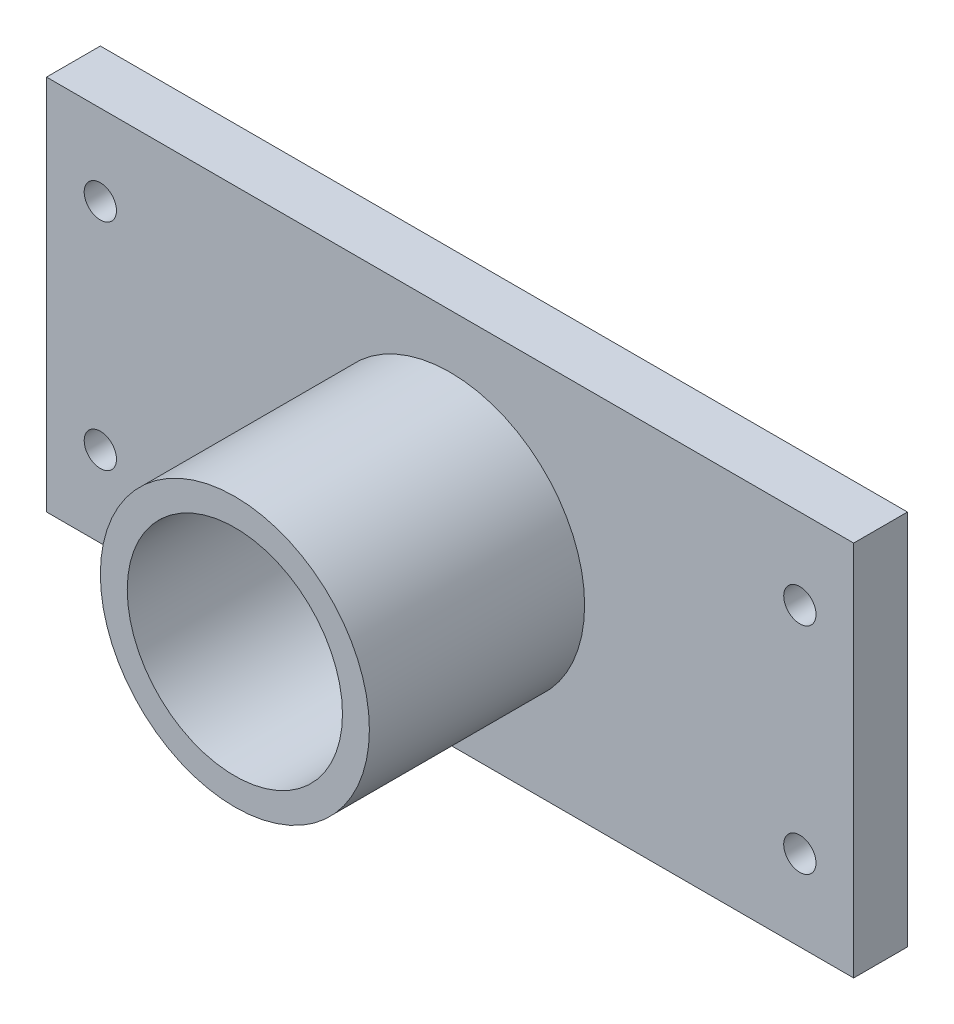
from build123d import *

# Parameters (mm, degrees)
SKETCH1_W           = 150
SKETCH1_H           = 70
SKETCH1_R           = 25
SKETCH1_R_2         = 20
BOSS_EXTRUDE1_DEPTH = 10
BOSS_EXTRUDE2_START = 10
SKETCH1_3_R         = 25
SKETCH1_3_R_2       = 20
BOSS_EXTRUDE2_DEPTH = 40
SKETCH6_R           = 3
CUT_EXTRUDE1_DEPTH  = 11


with BuildPart() as part:
    # Sketch1 → Boss-Extrude1 (new body)
    with BuildSketch(Plane.XY):
        Rectangle(SKETCH1_W, SKETCH1_H)
        Circle(SKETCH1_R, mode=Mode.SUBTRACT)
        Circle(SKETCH1_R)
        Circle(SKETCH1_R_2, mode=Mode.SUBTRACT)
    extrude(amount=BOSS_EXTRUDE1_DEPTH)

    # Sketch1_3 → Boss-Extrude2 (add)
    with BuildSketch(Plane.XY.offset(BOSS_EXTRUDE2_START)):
        Circle(SKETCH1_3_R)
        Circle(SKETCH1_3_R_2, mode=Mode.SUBTRACT)
    extrude(amount=BOSS_EXTRUDE2_DEPTH)

    # Sketch6 → Cut-Extrude1 (cut, through all)
    with BuildSketch(Plane.XY.offset(10)):
        with Locations((-65, 20)):
            Circle(SKETCH6_R)
        with Locations((-65, -20)):
            Circle(SKETCH6_R)
        with Locations((65, -20)):
            Circle(SKETCH6_R)
        with Locations((65, 20)):
            Circle(SKETCH6_R)
    extrude(amount=-CUT_EXTRUDE1_DEPTH, mode=Mode.SUBTRACT)


solid = part.part
